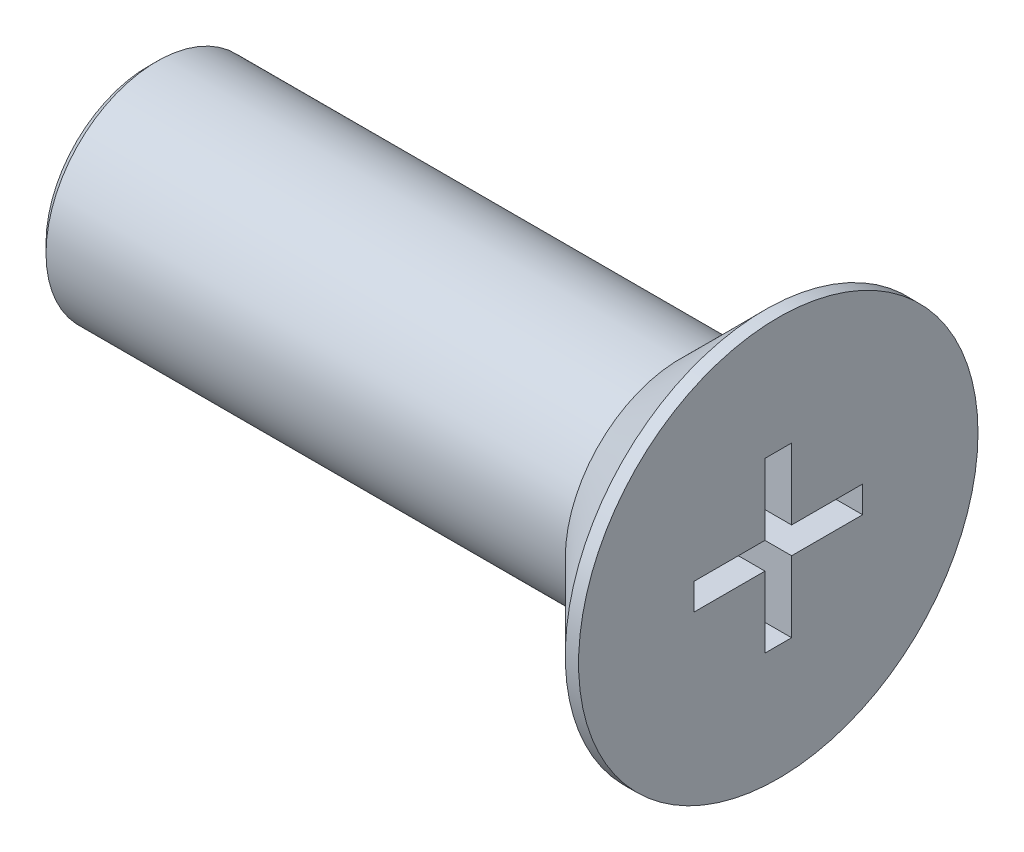
from build123d import *

# Parameters (mm, degrees)
SKETCH_1_R          = 4.5
EXTRUDE_1_DEPTH     = 2.2
SKETCH_2_R          = 2.5
EXTRUDE_3_DEPTH     = 12
CHAMFER_2_SIZE      = 0.2
CHAMFER_3_SIZE      = 1.9
CUT_EXTRUDE_2_DEPTH = 3


with BuildPart() as part:
    # 草图1 → 凸台-拉伸1 (new body)
    with BuildSketch(Plane(origin=(0, 0, 0), x_dir=(0, 0, -1), z_dir=(1, 0, 0))):
        Circle(SKETCH_1_R)
    extrude(amount=EXTRUDE_1_DEPTH)

    # 草图2 → 凸台-拉伸3 (add)
    with BuildSketch(Plane.ZY):
        Circle(SKETCH_2_R)
    extrude(amount=EXTRUDE_3_DEPTH)

    # 倒角2
    chamfer_2_edges = [part.edges().sort_by_distance(p)[0] for p in [
        (-12, 0, -2.5),
    ]]
    chamfer(chamfer_2_edges, length=CHAMFER_2_SIZE)

    # 倒角3
    chamfer_3_edges = [part.edges().sort_by_distance(p)[0] for p in [
        (0, 0, 4.5),
    ]]
    chamfer(chamfer_3_edges, length=CHAMFER_3_SIZE)

    # 草图5 → 切除-拉伸2 (cut)
    with BuildSketch(Plane(origin=(2.2, 0, 0), x_dir=(0, 0, -1), z_dir=(1, 0, 0))):
        Polygon((0.3, 0.3), (1.9, 0.3), (1.9, -0.3), (0.3, -0.3), (0.3, -1.9), (-0.3, -1.9), (-0.3, -0.3), (-1.9, -0.3), (-1.9, 0.3), (-0.3, 0.3), (-0.3, 1.9), (0.3, 1.9), align=None)
    extrude(amount=-CUT_EXTRUDE_2_DEPTH, mode=Mode.SUBTRACT)


solid = part.part
